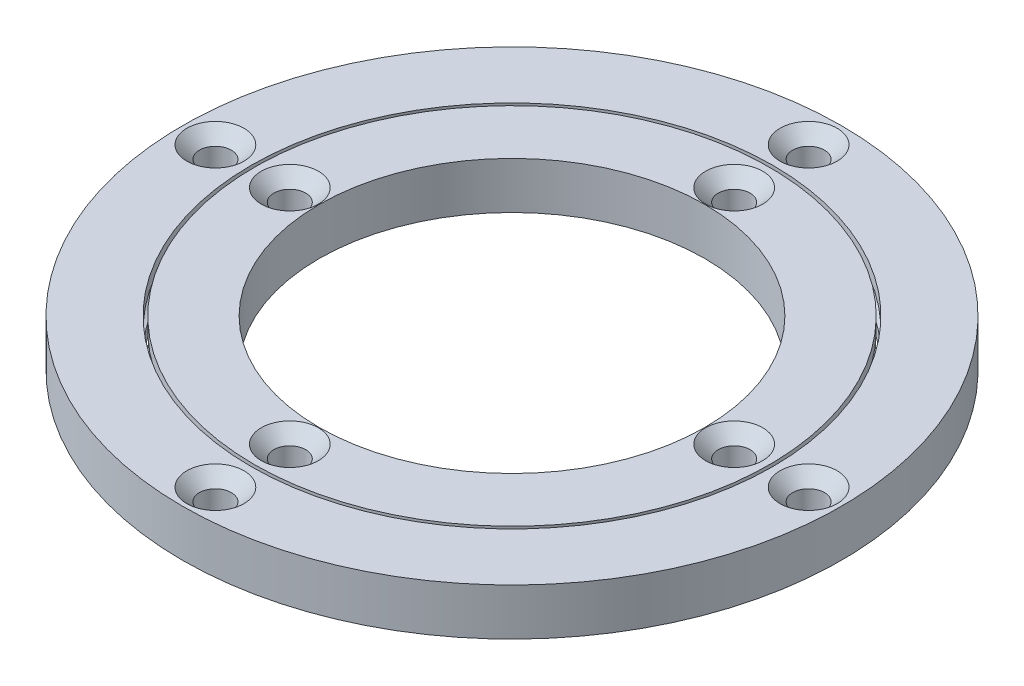
from build123d import *

# Parameters (mm, degrees)
SKETCH1_R                                      = 60
SKETCH1_R_2                                    = 47.5
BOSS_EXTRUDE1_DEPTH                            = 8.53
SKETCH2_R                                      = 46.89
SKETCH2_R_2                                    = 35.135
BOSS_EXTRUDE2_DEPTH                            = 8.53
CUT_SWEEP1_PROFILE_R                           = 2
CSK_FOR_M5_FLAT_HEAD_MACHINE_SCREW1_AT_2_COUNT = 2
CSK_FOR_M5_FLAT_HEAD_MACHINE_SCREW1_AT_2_PITCH = 13.549999997
CSK_FOR_M5_FLAT_HEAD_MACHINE_SCREW1_AT_3_COUNT = 2
CSK_FOR_M5_FLAT_HEAD_MACHINE_SCREW1_AT_3_PITCH = 67.470011855
CSK_FOR_M5_FLAT_HEAD_MACHINE_SCREW1_AT_4_COUNT = 2
CSK_FOR_M5_FLAT_HEAD_MACHINE_SCREW1_AT_4_PITCH = 76.367532364
CSK_FOR_M5_FLAT_HEAD_MACHINE_SCREW1_AT_5_COUNT = 2
CSK_FOR_M5_FLAT_HEAD_MACHINE_SCREW1_AT_5_PITCH = 67.470011855
CSK_FOR_M5_FLAT_HEAD_MACHINE_SCREW1_AT_6_COUNT = 2
CSK_FOR_M5_FLAT_HEAD_MACHINE_SCREW1_AT_6_PITCH = 76.367532364
CSK_FOR_M5_FLAT_HEAD_MACHINE_SCREW1_AT_7_COUNT = 2
CSK_FOR_M5_FLAT_HEAD_MACHINE_SCREW1_AT_7_PITCH = 94.449999997
CSK_FOR_M5_FLAT_HEAD_MACHINE_SCREW1_AT_8_COUNT = 2
CSK_FOR_M5_FLAT_HEAD_MACHINE_SCREW1_AT_8_PITCH = 107.999999994


with BuildPart() as part:
    # Sketch1 → Boss-Extrude1 (new body)
    with BuildSketch(Plane(origin=(0, 0, 0), x_dir=(1, 0, 0), z_dir=(0, 1, 0))):
        with Locations(Location((0, 0, 0), (0, 0, 270))):
            Circle(SKETCH1_R)
        with Locations(Location((0, 0, 0), (0, 0, 270))):
            Circle(SKETCH1_R_2, mode=Mode.SUBTRACT)
    extrude(amount=BOSS_EXTRUDE1_DEPTH)


with BuildPart() as body_2:
    # Sketch2 → Boss-Extrude2 (new body)
    with BuildSketch(Plane(origin=(0, 0, 0), x_dir=(1, 0, 0), z_dir=(0, 1, 0))):
        with Locations(Location((0, 0, 0), (0, 0, 270))):
            Circle(SKETCH2_R)
        with Locations(Location((0, 0, 0), (0, 0, 270))):
            Circle(SKETCH2_R_2, mode=Mode.SUBTRACT)
    extrude(amount=BOSS_EXTRUDE2_DEPTH)


with BuildPart() as cut_sweep1_tool:
    # Cut-Sweep1: sweep along a path in Sketch3
    with BuildLine(Plane(origin=(0, 4.265, 0), x_dir=(1, 0, 0), z_dir=(0, 1, 0))) as cut_sweep1_path:
        CenterArc((0, 0), 47.195, 0, 360)
    # Cut-Sweep1 profile (on start of the path) → Cut-Sweep1 (sweep)
    with BuildSketch(Plane(origin=(47.195, 4.265, 0), x_dir=(-1, 0, 0), z_dir=(0, 0, -1))):
        Circle(CUT_SWEEP1_PROFILE_R)
    sweep(path=cut_sweep1_path.line)


with BuildPart() as part_1:
    add(part.part)

    # Cut-Sweep1: cut by cut_sweep1_tool
    add(cut_sweep1_tool.part, mode=Mode.SUBTRACT)

    # Sketch33 → CSK for M5 Flat Head Machine Screw1 (revolve, cut)
    with BuildSketch(Plane(origin=(0, 8.53, -53.999999997), x_dir=(0, 0, 1), z_dir=(1, 0, 0))):
        Polygon((0, 0), (0, 8.53), (2.9, 8.53), (2.9, 2.3), (5.2, 0), align=None)
    csk_for_m5_flat_head_machine_screw1 = revolve(axis=Axis((0, 14.88, -53.999999997), (0, -1, 0)), mode=Mode.SUBTRACT)

    # CSK for M5 Flat Head Machine Screw1 at 4: CSK for M5 Flat Head Machine Screw1 ×2
    with Locations(*[Vector(0.7071067811865476, 0, 0.7071067811865476) * (i * CSK_FOR_M5_FLAT_HEAD_MACHINE_SCREW1_AT_4_PITCH) for i in range(1, CSK_FOR_M5_FLAT_HEAD_MACHINE_SCREW1_AT_4_COUNT)]):
        add(csk_for_m5_flat_head_machine_screw1, mode=Mode.SUBTRACT)

    # CSK for M5 Flat Head Machine Screw1 at 6: CSK for M5 Flat Head Machine Screw1 ×2
    with Locations(*[Vector(-0.7071067811865475, 0, 0.7071067811865476) * (i * CSK_FOR_M5_FLAT_HEAD_MACHINE_SCREW1_AT_6_PITCH) for i in range(1, CSK_FOR_M5_FLAT_HEAD_MACHINE_SCREW1_AT_6_COUNT)]):
        add(csk_for_m5_flat_head_machine_screw1, mode=Mode.SUBTRACT)

    # CSK for M5 Flat Head Machine Screw1 at 8: CSK for M5 Flat Head Machine Screw1 ×2
    with Locations(*[(0, 0, i * CSK_FOR_M5_FLAT_HEAD_MACHINE_SCREW1_AT_8_PITCH) for i in range(1, CSK_FOR_M5_FLAT_HEAD_MACHINE_SCREW1_AT_8_COUNT)]):
        add(csk_for_m5_flat_head_machine_screw1, mode=Mode.SUBTRACT)


with BuildPart() as body_2_1:
    add(body_2.part)

    # Cut-Sweep1: cut by cut_sweep1_tool
    add(cut_sweep1_tool.part, mode=Mode.SUBTRACT)

    # CSK for M5 Flat Head Machine Screw1 at 2: CSK for M5 Flat Head Machine Screw1 ×2
    with Locations(*[(0, 0, i * CSK_FOR_M5_FLAT_HEAD_MACHINE_SCREW1_AT_2_PITCH) for i in range(1, CSK_FOR_M5_FLAT_HEAD_MACHINE_SCREW1_AT_2_COUNT)]):
        add(csk_for_m5_flat_head_machine_screw1, mode=Mode.SUBTRACT)

    # CSK for M5 Flat Head Machine Screw1 at 3: CSK for M5 Flat Head Machine Screw1 ×2
    with Locations(*[Vector(0.5995256097938652, 0, 0.8003555729807186) * (i * CSK_FOR_M5_FLAT_HEAD_MACHINE_SCREW1_AT_3_PITCH) for i in range(1, CSK_FOR_M5_FLAT_HEAD_MACHINE_SCREW1_AT_3_COUNT)]):
        add(csk_for_m5_flat_head_machine_screw1, mode=Mode.SUBTRACT)

    # CSK for M5 Flat Head Machine Screw1 at 5: CSK for M5 Flat Head Machine Screw1 ×2
    with Locations(*[Vector(-0.599525609793865, 0, 0.8003555729807185) * (i * CSK_FOR_M5_FLAT_HEAD_MACHINE_SCREW1_AT_5_PITCH) for i in range(1, CSK_FOR_M5_FLAT_HEAD_MACHINE_SCREW1_AT_5_COUNT)]):
        add(csk_for_m5_flat_head_machine_screw1, mode=Mode.SUBTRACT)

    # CSK for M5 Flat Head Machine Screw1 at 7: CSK for M5 Flat Head Machine Screw1 ×2
    with Locations(*[(0, 0, i * CSK_FOR_M5_FLAT_HEAD_MACHINE_SCREW1_AT_7_PITCH) for i in range(1, CSK_FOR_M5_FLAT_HEAD_MACHINE_SCREW1_AT_7_COUNT)]):
        add(csk_for_m5_flat_head_machine_screw1, mode=Mode.SUBTRACT)


solid = Compound([part_1.part, body_2_1.part])
